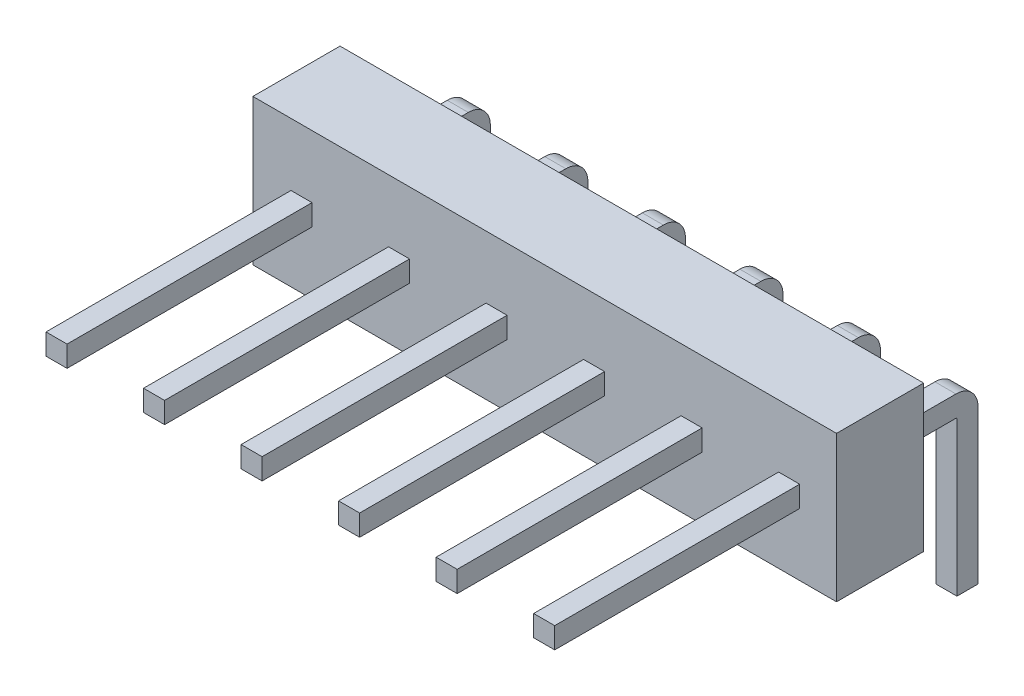
from build123d import *

# Parameters (mm, degrees)
SKETCH1_W           = 15.2
SKETCH1_H           = 2.27
BOSS_EXTRUDE1_DEPTH = 3.8
SKETCH2_W           = 0.548157429
SKETCH2_H           = 0.54815743
SKETCH2_2_W         = 0.548157429
SKETCH2_2_H         = 0.54815743
BOSS_EXTRUDE2_DEPTH = 8.65


with BuildPart() as part:
    # Sketch1 → Boss-Extrude1 (new body)
    with BuildSketch(Plane(origin=(0, 0, 0), x_dir=(1, 0, 0), z_dir=(0, 1, 0))):
        with Locations((7.6, 1.135)):
            Rectangle(SKETCH1_W, SKETCH1_H)
    extrude(amount=BOSS_EXTRUDE1_DEPTH)

    # Sweep1: sweep along a path in Sketch3
    with BuildLine(Plane(origin=(0, 0, 0), x_dir=(0, 0, -1), z_dir=(1, 0, 0))) as sweep1_path:
        Line((2.27, 1.9), (4.07, 1.9))
        ThreePointArc((4.07, 1.9), (4.282132034, 1.812132034), (4.37, 1.6))
        Line((4.37, 1.6), (4.37, -2.4))
    # Sketch2 → Sweep1 (sweep)
    with BuildSketch(Plane(origin=(0, 0, -2.27), x_dir=(-1, 0, 0), z_dir=(0, 0, -1))):
        with Locations((-1.266407872, 1.9)):
            Rectangle(SKETCH2_W, SKETCH2_H)
        with Locations((-3.806407872, 1.9)):
            Rectangle(SKETCH2_W, SKETCH2_H)
        with Locations((-6.346407872, 1.9)):
            Rectangle(SKETCH2_W, SKETCH2_H)
        with Locations((-8.886407872, 1.9)):
            Rectangle(SKETCH2_W, SKETCH2_H)
        with Locations((-11.426407872, 1.9)):
            Rectangle(SKETCH2_W, SKETCH2_H)
        with Locations((-13.966407872, 1.9)):
            Rectangle(SKETCH2_W, SKETCH2_H)
    sweep(path=sweep1_path.line)

    # Sketch2_2 → Boss-Extrude2 (add)
    with BuildSketch(Plane(origin=(0, 0, -2.27), x_dir=(-1, 0, 0), z_dir=(0, 0, -1))):
        with Locations((-1.266407872, 1.9)):
            Rectangle(SKETCH2_2_W, SKETCH2_2_H)
        with Locations((-3.806407872, 1.9)):
            Rectangle(SKETCH2_2_W, SKETCH2_2_H)
        with Locations((-6.346407872, 1.9)):
            Rectangle(SKETCH2_2_W, SKETCH2_2_H)
        with Locations((-8.886407872, 1.9)):
            Rectangle(SKETCH2_2_W, SKETCH2_2_H)
        with Locations((-11.426407872, 1.9)):
            Rectangle(SKETCH2_2_W, SKETCH2_2_H)
        with Locations((-13.966407872, 1.9)):
            Rectangle(SKETCH2_2_W, SKETCH2_2_H)
    extrude(amount=-BOSS_EXTRUDE2_DEPTH)


solid = part.part
